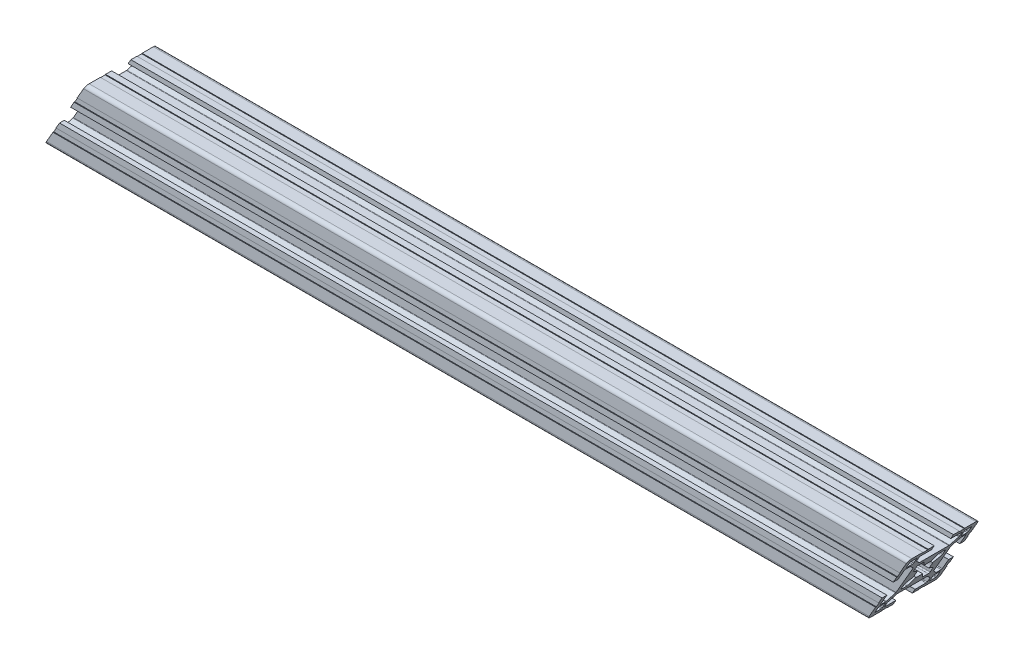
from build123d import *

# Parameters (mm, degrees)
QUADRADO_PF30_11_PERFIL_3030_CENTRO_M8_DEPTH = 363.73
CORTE_EXTRUS_O1_DEPTH                        = 365.348065255
CORTE_EXTRUS_O1_DEPTH_BACK                   = 365.348065255


with BuildPart() as part:
    # Sketch1 → Quadrado PF30-11 - PERFIL 3030 CENTRO M8(1) (new body)
    with BuildSketch(Plane.YZ):
        with BuildLine():
            Line((14.999995923, 6.599996803), (14.699995923, 6.599996803))
            Line((14.699995923, 6.599996803), (14.699995923, 8.799996803))
            Line((14.699995923, 8.799996803), (14.999995923, 8.799996803))
            Line((14.999995923, 8.799996803), (14.999995923, 13.499995825))
            ThreePointArc((14.999995923, 13.499995825), (14.560656066, 14.560656066), (13.499995825, 14.999995923))
            Line((13.499995825, 14.999995923), (8.799996818, 14.999995923))
            Line((8.799996818, 14.999995923), (8.799996818, 14.699995923))
            Line((8.799996818, 14.699995923), (6.599996818, 14.699995923))
            Line((6.599996818, 14.699995923), (6.599996818, 14.999995923))
            Line((6.599996818, 14.999995923), (4.0499987, 14.999995923))
            Line((4.0499987, 14.999995923), (4.0499987, 12.999995366))
            Line((4.0499987, 12.999995366), (8.699997649, 12.999995366))
            ThreePointArc((8.699997649, 12.999995366), (8.912129683, 12.9121274), (8.999997649, 12.699995366))
            Line((8.999997649, 12.699995366), (8.999997649, 10.679894006))
            ThreePointArc((8.999997649, 10.679894006), (8.977161511, 10.565088981), (8.912129691, 10.467761979))
            Line((8.912129691, 10.467761979), (6.432230191, 7.987862303))
            ThreePointArc((6.432230191, 7.987862303), (6.334903184, 7.922830472), (6.220098149, 7.89999433))
            Line((6.220098149, 7.89999433), (-6.220098149, 7.89999433))
            ThreePointArc((-6.220098149, 7.89999433), (-6.334903184, 7.922830472), (-6.432230191, 7.987862303))
            Line((-6.432230191, 7.987862303), (-8.912129691, 10.467761979))
            ThreePointArc((-8.912129691, 10.467761979), (-8.977161511, 10.565088981), (-8.999997649, 10.679894006))
            Line((-8.999997649, 10.679894006), (-8.999997649, 12.699995366))
            ThreePointArc((-8.999997649, 12.699995366), (-8.912129683, 12.9121274), (-8.699997649, 12.999995366))
            Line((-8.699997649, 12.999995366), (-4.0499987, 12.999995366))
            Line((-4.0499987, 12.999995366), (-4.0499987, 14.999995923))
            Line((-4.0499987, 14.999995923), (-6.599996818, 14.999995923))
            Line((-6.599996818, 14.999995923), (-6.599996818, 14.699995923))
            Line((-6.599996818, 14.699995923), (-8.799996818, 14.699995923))
            Line((-8.799996818, 14.699995923), (-8.799996818, 14.999995923))
            Line((-8.799996818, 14.999995923), (-13.499995825, 14.999995923))
            ThreePointArc((-13.499995825, 14.999995923), (-14.560656066, 14.560656066), (-14.999995923, 13.499995825))
            Line((-14.999995923, 13.499995825), (-14.999995923, 8.799996803))
            Line((-14.999995923, 8.799996803), (-14.699995923, 8.799996803))
            Line((-14.699995923, 8.799996803), (-14.699995923, 6.599996803))
            Line((-14.699995923, 6.599996803), (-14.999995923, 6.599996803))
            Line((-14.999995923, 6.599996803), (-14.999995923, 4.0499987))
            Line((-14.999995923, 4.0499987), (-12.999995366, 4.0499987))
            Line((-12.999995366, 4.0499987), (-12.999995366, 8.699997649))
            ThreePointArc((-12.999995366, 8.699997649), (-12.9121274, 8.912129683), (-12.699995366, 8.999997649))
            Line((-12.699995366, 8.999997649), (-10.679894006, 8.999997649))
            ThreePointArc((-10.679894006, 8.999997649), (-10.565088981, 8.977161511), (-10.467761979, 8.912129691))
            Line((-10.467761979, 8.912129691), (-7.987862303, 6.432230191))
            ThreePointArc((-7.987862303, 6.432230191), (-7.922830472, 6.334903184), (-7.89999433, 6.220098149))
            Line((-7.89999433, 6.220098149), (-7.89999433, -6.220098149))
            ThreePointArc((-7.89999433, -6.220098149), (-7.922830472, -6.334903184), (-7.987862303, -6.432230191))
            Line((-7.987862303, -6.432230191), (-10.467761979, -8.912129691))
            ThreePointArc((-10.467761979, -8.912129691), (-10.565088981, -8.977161511), (-10.679894006, -8.999997649))
            Line((-10.679894006, -8.999997649), (-12.699995366, -8.999997649))
            ThreePointArc((-12.699995366, -8.999997649), (-12.9121274, -8.912129683), (-12.999995366, -8.699997649))
            Line((-12.999995366, -8.699997649), (-12.999995366, -4.0499987))
            Line((-12.999995366, -4.0499987), (-14.999995923, -4.0499987))
            Line((-14.999995923, -4.0499987), (-14.999995923, -6.599996803))
            Line((-14.999995923, -6.599996803), (-14.699995923, -6.599996803))
            Line((-14.699995923, -6.599996803), (-14.699995923, -8.799996803))
            Line((-14.699995923, -8.799996803), (-14.999995923, -8.799996803))
            Line((-14.999995923, -8.799996803), (-14.999995923, -13.499995825))
            ThreePointArc((-14.999995923, -13.499995825), (-14.560656066, -14.560656066), (-13.499995825, -14.999995923))
            Line((-13.499995825, -14.999995923), (-8.799996818, -14.999995923))
            Line((-8.799996818, -14.999995923), (-8.799996818, -14.699995923))
            Line((-8.799996818, -14.699995923), (-6.599996818, -14.699995923))
            Line((-6.599996818, -14.699995923), (-6.599996818, -14.999995923))
            Line((-6.599996818, -14.999995923), (-4.0499987, -14.999995923))
            Line((-4.0499987, -14.999995923), (-4.0499987, -12.999995366))
            Line((-4.0499987, -12.999995366), (-8.699997649, -12.999995366))
            ThreePointArc((-8.699997649, -12.999995366), (-8.912129683, -12.9121274), (-8.999997649, -12.699995366))
            Line((-8.999997649, -12.699995366), (-8.999997649, -10.679894006))
            ThreePointArc((-8.999997649, -10.679894006), (-8.977161511, -10.565088981), (-8.912129691, -10.467761979))
            Line((-8.912129691, -10.467761979), (-6.432230191, -7.987862303))
            ThreePointArc((-6.432230191, -7.987862303), (-6.334903184, -7.922830472), (-6.220098149, -7.89999433))
            Line((-6.220098149, -7.89999433), (6.220098149, -7.89999433))
            ThreePointArc((6.220098149, -7.89999433), (6.334903184, -7.922830472), (6.432230191, -7.987862303))
            Line((6.432230191, -7.987862303), (8.912129691, -10.467761979))
            ThreePointArc((8.912129691, -10.467761979), (8.977161511, -10.565088981), (8.999997649, -10.679894006))
            Line((8.999997649, -10.679894006), (8.999997649, -12.699995366))
            ThreePointArc((8.999997649, -12.699995366), (8.912129683, -12.9121274), (8.699997649, -12.999995366))
            Line((8.699997649, -12.999995366), (4.0499987, -12.999995366))
            Line((4.0499987, -12.999995366), (4.0499987, -14.999995923))
            Line((4.0499987, -14.999995923), (6.599996818, -14.999995923))
            Line((6.599996818, -14.999995923), (6.599996818, -14.699995923))
            Line((6.599996818, -14.699995923), (8.799996818, -14.699995923))
            Line((8.799996818, -14.699995923), (8.799996818, -14.999995923))
            Line((8.799996818, -14.999995923), (13.499995825, -14.999995923))
            ThreePointArc((13.499995825, -14.999995923), (14.560656066, -14.560656066), (14.999995923, -13.499995825))
            Line((14.999995923, -13.499995825), (14.999995923, -8.799996803))
            Line((14.999995923, -8.799996803), (14.699995923, -8.799996803))
            Line((14.699995923, -8.799996803), (14.699995923, -6.599996803))
            Line((14.699995923, -6.599996803), (14.999995923, -6.599996803))
            Line((14.999995923, -6.599996803), (14.999995923, -4.0499987))
            Line((14.999995923, -4.0499987), (12.999995366, -4.0499987))
            Line((12.999995366, -4.0499987), (12.999995366, -8.699997649))
            ThreePointArc((12.999995366, -8.699997649), (12.9121274, -8.912129683), (12.699995366, -8.999997649))
            Line((12.699995366, -8.999997649), (10.679894006, -8.999997649))
            ThreePointArc((10.679894006, -8.999997649), (10.565088981, -8.977161511), (10.467761979, -8.912129691))
            Line((10.467761979, -8.912129691), (7.987862303, -6.432230191))
            ThreePointArc((7.987862303, -6.432230191), (7.922830472, -6.334903184), (7.89999433, -6.220098149))
            Line((7.89999433, -6.220098149), (7.89999433, 6.220098149))
            ThreePointArc((7.89999433, 6.220098149), (7.922830472, 6.334903184), (7.987862303, 6.432230191))
            Line((7.987862303, 6.432230191), (10.467761979, 8.912129691))
            ThreePointArc((10.467761979, 8.912129691), (10.565088981, 8.977161511), (10.679894006, 8.999997649))
            Line((10.679894006, 8.999997649), (12.699995366, 8.999997649))
            ThreePointArc((12.699995366, 8.999997649), (12.9121274, 8.912129683), (12.999995366, 8.699997649))
            Line((12.999995366, 8.699997649), (12.999995366, 4.0499987))
            Line((12.999995366, 4.0499987), (14.999995923, 4.0499987))
            Line((14.999995923, 4.0499987), (14.999995923, 6.599996803))
        make_face()
        with BuildLine():
            Line((-6.1, -3.425408784), (-6.1, -5.6))
            ThreePointArc((-6.1, -5.6), (-5.953553391, -5.953553391), (-5.6, -6.1))
            Line((-5.6, -6.1), (-3.425408784, -6.1))
            ThreePointArc((-3.425408784, -6.1), (-3.175408784, -6.033012702), (-2.992396082, -5.85))
            Line((-2.992396082, -5.85), (-1.402974441, -3.097040962))
            ThreePointArc((-1.402974441, -3.097040962), (0, -3.4), (1.402974441, -3.097040962))
            Line((1.402974441, -3.097040962), (2.992396082, -5.85))
            ThreePointArc((2.992396082, -5.85), (3.175408784, -6.033012702), (3.425408784, -6.1))
            Line((3.425408784, -6.1), (5.6, -6.1))
            ThreePointArc((5.6, -6.1), (5.953553391, -5.953553391), (6.1, -5.6))
            Line((6.1, -5.6), (6.1, -3.425408784))
            ThreePointArc((6.1, -3.425408784), (6.033012702, -3.175408784), (5.85, -2.992396082))
            Line((5.85, -2.992396082), (3.097040962, -1.402974441))
            ThreePointArc((3.097040962, -1.402974441), (3.4, 0), (3.097040962, 1.402974441))
            Line((3.097040962, 1.402974441), (5.85, 2.992396082))
            ThreePointArc((5.85, 2.992396082), (6.033012702, 3.175408784), (6.1, 3.425408784))
            Line((6.1, 3.425408784), (6.1, 5.6))
            ThreePointArc((6.1, 5.6), (5.953553391, 5.953553391), (5.6, 6.1))
            Line((5.6, 6.1), (3.425408784, 6.1))
            ThreePointArc((3.425408784, 6.1), (3.175408784, 6.033012702), (2.992396082, 5.85))
            Line((2.992396082, 5.85), (1.402974441, 3.097040962))
            ThreePointArc((1.402974441, 3.097040962), (0, 3.4), (-1.402974441, 3.097040962))
            Line((-1.402974441, 3.097040962), (-2.992396082, 5.85))
            ThreePointArc((-2.992396082, 5.85), (-3.175408784, 6.033012702), (-3.425408784, 6.1))
            Line((-3.425408784, 6.1), (-5.6, 6.1))
            ThreePointArc((-5.6, 6.1), (-5.953553391, 5.953553391), (-6.1, 5.6))
            Line((-6.1, 5.6), (-6.1, 3.425408784))
            ThreePointArc((-6.1, 3.425408784), (-6.033012702, 3.175408784), (-5.85, 2.992396082))
            Line((-5.85, 2.992396082), (-3.097040962, 1.402974441))
            ThreePointArc((-3.097040962, 1.402974441), (-3.4, 0), (-3.097040962, -1.402974441))
            Line((-3.097040962, -1.402974441), (-5.85, -2.992396082))
            ThreePointArc((-5.85, -2.992396082), (-6.033012702, -3.175408784), (-6.1, -3.425408784))
        make_face(mode=Mode.SUBTRACT)
        with BuildLine():
            Line((9.999995366, 12.699997649), (9.999995366, 10.299997649))
            ThreePointArc((9.999995366, 10.299997649), (10.087863331, 10.087865615), (10.299995366, 9.999997649))
            Line((10.299995366, 9.999997649), (12.699995366, 9.999997649))
            ThreePointArc((12.699995366, 9.999997649), (12.9121274, 10.087865615), (12.999995366, 10.299997649))
            Line((12.999995366, 10.299997649), (12.999995366, 12.699997649))
            ThreePointArc((12.999995366, 12.699997649), (12.9121274, 12.912129683), (12.699995366, 12.999997649))
            Line((12.699995366, 12.999997649), (10.299995366, 12.999997649))
            ThreePointArc((10.299995366, 12.999997649), (10.087863331, 12.912129683), (9.999995366, 12.699997649))
        make_face(mode=Mode.SUBTRACT)
        with BuildLine():
            Line((12.999995366, -12.699997649), (12.999995366, -10.299997649))
            ThreePointArc((12.999995366, -10.299997649), (12.9121274, -10.087865615), (12.699995366, -9.999997649))
            Line((12.699995366, -9.999997649), (10.299995366, -9.999997649))
            ThreePointArc((10.299995366, -9.999997649), (10.087863331, -10.087865615), (9.999995366, -10.299997649))
            Line((9.999995366, -10.299997649), (9.999995366, -12.699997649))
            ThreePointArc((9.999995366, -12.699997649), (10.087863331, -12.912129683), (10.299995366, -12.999997649))
            Line((10.299995366, -12.999997649), (12.699995366, -12.999997649))
            ThreePointArc((12.699995366, -12.999997649), (12.9121274, -12.912129683), (12.999995366, -12.699997649))
        make_face(mode=Mode.SUBTRACT)
        with BuildLine():
            Line((-10.299995366, -9.999997649), (-12.699995366, -9.999997649))
            ThreePointArc((-12.699995366, -9.999997649), (-12.9121274, -10.087865615), (-12.999995366, -10.299997649))
            Line((-12.999995366, -10.299997649), (-12.999995366, -12.699997649))
            ThreePointArc((-12.999995366, -12.699997649), (-12.9121274, -12.912129683), (-12.699995366, -12.999997649))
            Line((-12.699995366, -12.999997649), (-10.299995366, -12.999997649))
            ThreePointArc((-10.299995366, -12.999997649), (-10.087863331, -12.912129683), (-9.999995366, -12.699997649))
            Line((-9.999995366, -12.699997649), (-9.999995366, -10.299997649))
            ThreePointArc((-9.999995366, -10.299997649), (-10.087863331, -10.087865615), (-10.299995366, -9.999997649))
        make_face(mode=Mode.SUBTRACT)
        with BuildLine():
            Line((-12.999995366, 12.699997649), (-12.999995366, 10.299997649))
            ThreePointArc((-12.999995366, 10.299997649), (-12.9121274, 10.087865615), (-12.699995366, 9.999997649))
            Line((-12.699995366, 9.999997649), (-10.299995366, 9.999997649))
            ThreePointArc((-10.299995366, 9.999997649), (-10.087863331, 10.087865615), (-9.999995366, 10.299997649))
            Line((-9.999995366, 10.299997649), (-9.999995366, 12.699997649))
            ThreePointArc((-9.999995366, 12.699997649), (-10.087863331, 12.912129683), (-10.299995366, 12.999997649))
            Line((-10.299995366, 12.999997649), (-12.699995366, 12.999997649))
            ThreePointArc((-12.699995366, 12.999997649), (-12.9121274, 12.912129683), (-12.999995366, 12.699997649))
        make_face(mode=Mode.SUBTRACT)
    extrude(amount=QUADRADO_PF30_11_PERFIL_3030_CENTRO_M8_DEPTH)

    # Esboço2 → Corte-extrusão1 (cut, two sides)
    with BuildSketch(Plane.XY) as corte_extrus_o1_sk:
        Polygon((363.73, 14.999995923), (346.409496632, -14.999995923), (363.73, -14.999995923), align=None)
        Polygon((0, -14.999995923), (0, 14.999995923), (17.320503368, 14.999995923), align=None)
    extrude(amount=CORTE_EXTRUS_O1_DEPTH, mode=Mode.SUBTRACT)
    extrude(corte_extrus_o1_sk.sketch, amount=-CORTE_EXTRUS_O1_DEPTH_BACK, mode=Mode.SUBTRACT)


solid = part.part
